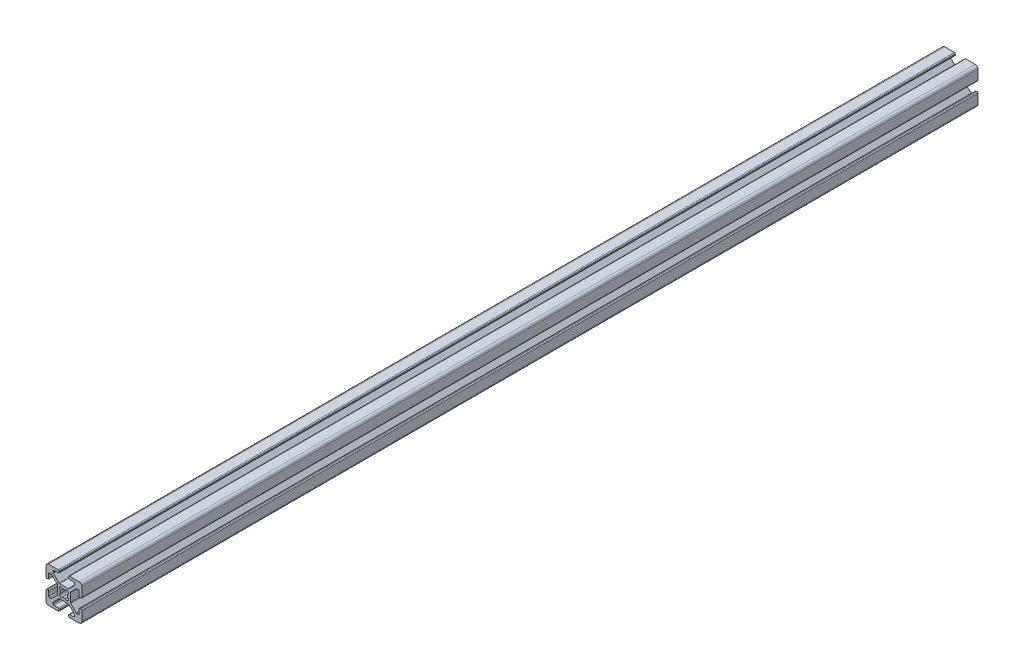
from build123d import *

# Parameters (mm, degrees)
EXTRUDE1_DEPTH = 500


with BuildPart() as part:
    # Sketch1 → Extrude1 (new body)
    with BuildSketch(Plane.XY):
        with BuildLine():
            Line((-5.032287798, -0.341059771), (-5.516287798, -0.341059771))
            ThreePointArc((-5.516287798, -0.341059771), (-5.875498042, -0.192270016), (-6.024287798, 0.166940229))
            Line((-6.024287798, 0.166940229), (-6.024287798, 2.515940229))
            ThreePointArc((-6.024287798, 2.515940229), (-6.173077553, 2.875150474), (-6.532287798, 3.023940229))
            Line((-6.532287798, 3.023940229), (-7.258207136, 3.023940229))
            ThreePointArc((-7.258207136, 3.023940229), (-7.45261032, 2.985271032), (-7.617417381, 2.875150474))
            Line((-7.617417381, 2.875150474), (-10.720498042, -0.227930187))
            ThreePointArc((-10.720498042, -0.227930187), (-10.8306186, -0.392737249), (-10.869287798, -0.587140432))
            Line((-10.869287798, -0.587140432), (-10.869287798, -5.354979109))
            ThreePointArc((-10.869287798, -5.354979109), (-10.8306186, -5.549382293), (-10.720498042, -5.714189354))
            Line((-10.720498042, -5.714189354), (-7.617417381, -8.817270016))
            ThreePointArc((-7.617417381, -8.817270016), (-7.45261032, -8.927390573), (-7.258207136, -8.966059771))
            Line((-7.258207136, -8.966059771), (-6.532287798, -8.966059771))
            ThreePointArc((-6.532287798, -8.966059771), (-6.173077553, -8.817270016), (-6.024287798, -8.458059771))
            Line((-6.024287798, -8.458059771), (-6.024287798, -6.109059771))
            ThreePointArc((-6.024287798, -6.109059771), (-5.875498042, -5.749849526), (-5.516287798, -5.601059771))
            Line((-5.516287798, -5.601059771), (-5.032287798, -5.601059771))
            ThreePointArc((-5.032287798, -5.601059771), (-4.673077553, -5.749849526), (-4.524287798, -6.109059771))
            Line((-4.524287798, -6.109059771), (-4.524287798, -11.471059771))
            ThreePointArc((-4.524287798, -11.471059771), (-4.963627626, -12.531719943), (-6.024287798, -12.971059771))
            Line((-6.024287798, -12.971059771), (-11.386287798, -12.971059771))
            ThreePointArc((-11.386287798, -12.971059771), (-11.745498042, -12.822270016), (-11.894287798, -12.463059771))
            Line((-11.894287798, -12.463059771), (-11.894287798, -11.979059771))
            ThreePointArc((-11.894287798, -11.979059771), (-11.745498042, -11.619849526), (-11.386287798, -11.471059771))
            Line((-11.386287798, -11.471059771), (-9.037287798, -11.471059771))
            ThreePointArc((-9.037287798, -11.471059771), (-8.678077553, -11.322270016), (-8.529287798, -10.963059771))
            Line((-8.529287798, -10.963059771), (-8.529287798, -10.237140432))
            ThreePointArc((-8.529287798, -10.237140432), (-8.567956995, -10.042737249), (-8.678077553, -9.877930187))
            Line((-8.678077553, -9.877930187), (-11.781158214, -6.774849526))
            ThreePointArc((-11.781158214, -6.774849526), (-11.945965275, -6.664728968), (-12.140368459, -6.626059771))
            Line((-12.140368459, -6.626059771), (-16.908207136, -6.626059771))
            ThreePointArc((-16.908207136, -6.626059771), (-17.10261032, -6.664728968), (-17.267417381, -6.774849526))
            Line((-17.267417381, -6.774849526), (-20.370498042, -9.877930187))
            ThreePointArc((-20.370498042, -9.877930187), (-20.4806186, -10.042737249), (-20.519287798, -10.237140432))
            Line((-20.519287798, -10.237140432), (-20.519287798, -10.963059771))
            ThreePointArc((-20.519287798, -10.963059771), (-20.370498042, -11.322270016), (-20.011287798, -11.471059771))
            Line((-20.011287798, -11.471059771), (-17.662287798, -11.471059771))
            ThreePointArc((-17.662287798, -11.471059771), (-17.303077553, -11.619849526), (-17.154287798, -11.979059771))
            Line((-17.154287798, -11.979059771), (-17.154287798, -12.463059771))
            ThreePointArc((-17.154287798, -12.463059771), (-17.303077553, -12.822270016), (-17.662287798, -12.971059771))
            Line((-17.662287798, -12.971059771), (-23.024287798, -12.971059771))
            ThreePointArc((-23.024287798, -12.971059771), (-24.084947969, -12.531719943), (-24.524287798, -11.471059771))
            Line((-24.524287798, -11.471059771), (-24.524287798, -6.109059771))
            ThreePointArc((-24.524287798, -6.109059771), (-24.375498042, -5.749849526), (-24.016287798, -5.601059771))
            Line((-24.016287798, -5.601059771), (-23.532287798, -5.601059771))
            ThreePointArc((-23.532287798, -5.601059771), (-23.173077553, -5.749849526), (-23.024287798, -6.109059771))
            Line((-23.024287798, -6.109059771), (-23.024287798, -8.458059771))
            ThreePointArc((-23.024287798, -8.458059771), (-22.875498042, -8.817270016), (-22.516287798, -8.966059771))
            Line((-22.516287798, -8.966059771), (-21.790368459, -8.966059771))
            ThreePointArc((-21.790368459, -8.966059771), (-21.595965275, -8.927390573), (-21.431158214, -8.817270016))
            Line((-21.431158214, -8.817270016), (-18.328077553, -5.714189354))
            ThreePointArc((-18.328077553, -5.714189354), (-18.217956995, -5.549382293), (-18.179287798, -5.354979109))
            Line((-18.179287798, -5.354979109), (-18.179287798, -0.587140432))
            ThreePointArc((-18.179287798, -0.587140432), (-18.217956995, -0.392737249), (-18.328077553, -0.227930187))
            Line((-18.328077553, -0.227930187), (-21.431158214, 2.875150474))
            ThreePointArc((-21.431158214, 2.875150474), (-21.595965275, 2.985271032), (-21.790368459, 3.023940229))
            Line((-21.790368459, 3.023940229), (-22.516287798, 3.023940229))
            ThreePointArc((-22.516287798, 3.023940229), (-22.875498042, 2.875150474), (-23.024287798, 2.515940229))
            Line((-23.024287798, 2.515940229), (-23.024287798, 0.166940229))
            ThreePointArc((-23.024287798, 0.166940229), (-23.173077553, -0.192270016), (-23.532287798, -0.341059771))
            Line((-23.532287798, -0.341059771), (-24.016287798, -0.341059771))
            ThreePointArc((-24.016287798, -0.341059771), (-24.375498042, -0.192270016), (-24.524287798, 0.166940229))
            Line((-24.524287798, 0.166940229), (-24.524287798, 5.528940229))
            ThreePointArc((-24.524287798, 5.528940229), (-24.084947969, 6.589600401), (-23.024287798, 7.028940229))
            Line((-23.024287798, 7.028940229), (-17.662287798, 7.028940229))
            ThreePointArc((-17.662287798, 7.028940229), (-17.303077553, 6.880150474), (-17.154287798, 6.520940229))
            Line((-17.154287798, 6.520940229), (-17.154287798, 6.036940229))
            ThreePointArc((-17.154287798, 6.036940229), (-17.303077553, 5.677729984), (-17.662287798, 5.528940229))
            Line((-17.662287798, 5.528940229), (-20.011287798, 5.528940229))
            ThreePointArc((-20.011287798, 5.528940229), (-20.370498042, 5.380150474), (-20.519287798, 5.020940229))
            Line((-20.519287798, 5.020940229), (-20.519287798, 4.295020891))
            ThreePointArc((-20.519287798, 4.295020891), (-20.4806186, 4.100617707), (-20.370498042, 3.935810646))
            Line((-20.370498042, 3.935810646), (-17.267417381, 0.832729984))
            ThreePointArc((-17.267417381, 0.832729984), (-17.10261032, 0.722609427), (-16.908207136, 0.683940229))
            Line((-16.908207136, 0.683940229), (-12.140368459, 0.683940229))
            ThreePointArc((-12.140368459, 0.683940229), (-11.945965275, 0.722609427), (-11.781158214, 0.832729984))
            Line((-11.781158214, 0.832729984), (-8.678077553, 3.935810646))
            ThreePointArc((-8.678077553, 3.935810646), (-8.567956995, 4.100617707), (-8.529287798, 4.295020891))
            Line((-8.529287798, 4.295020891), (-8.529287798, 5.020940229))
            ThreePointArc((-8.529287798, 5.020940229), (-8.678077553, 5.380150474), (-9.037287798, 5.528940229))
            Line((-9.037287798, 5.528940229), (-11.386287798, 5.528940229))
            ThreePointArc((-11.386287798, 5.528940229), (-11.745498042, 5.677729984), (-11.894287798, 6.036940229))
            Line((-11.894287798, 6.036940229), (-11.894287798, 6.520940229))
            ThreePointArc((-11.894287798, 6.520940229), (-11.745498042, 6.880150474), (-11.386287798, 7.028940229))
            Line((-11.386287798, 7.028940229), (-6.024287798, 7.028940229))
            ThreePointArc((-6.024287798, 7.028940229), (-4.963627626, 6.589600401), (-4.524287798, 5.528940229))
            Line((-4.524287798, 5.528940229), (-4.524287798, 0.166940229))
            ThreePointArc((-4.524287798, 0.166940229), (-4.673077553, -0.192270016), (-5.032287798, -0.341059771))
        make_face()
        with BuildLine():
            Line((-12.399386954, -5.275565737), (-12.219781831, -5.095960615))
            ThreePointArc((-12.219781831, -5.095960615), (-12.018349781, -4.327527582), (-12.589154291, -3.775036489))
            ThreePointArc((-12.589154291, -3.775036489), (-12.428787798, -2.971059771), (-12.589154291, -2.167083053))
            ThreePointArc((-12.589154291, -2.167083053), (-12.018349781, -1.61459196), (-12.219781831, -0.846158927))
            Line((-12.219781831, -0.846158927), (-12.399386954, -0.666553805))
            ThreePointArc((-12.399386954, -0.666553805), (-13.167819987, -0.465121754), (-13.72031108, -1.035926265))
            ThreePointArc((-13.72031108, -1.035926265), (-14.524287798, -0.875559771), (-15.328264516, -1.035926265))
            ThreePointArc((-15.328264516, -1.035926265), (-15.880755608, -0.465121754), (-16.649188641, -0.666553805))
            Line((-16.649188641, -0.666553805), (-16.828793764, -0.846158927))
            ThreePointArc((-16.828793764, -0.846158927), (-17.030225814, -1.61459196), (-16.459421304, -2.167083053))
            ThreePointArc((-16.459421304, -2.167083053), (-16.619787798, -2.971059771), (-16.459421304, -3.775036489))
            ThreePointArc((-16.459421304, -3.775036489), (-17.030225814, -4.327527582), (-16.828793764, -5.095960615))
            Line((-16.828793764, -5.095960615), (-16.649188641, -5.275565737))
            ThreePointArc((-16.649188641, -5.275565737), (-15.880755608, -5.476997788), (-15.328264516, -4.906193277))
            ThreePointArc((-15.328264516, -4.906193277), (-14.524287798, -5.066559771), (-13.72031108, -4.906193277))
            ThreePointArc((-13.72031108, -4.906193277), (-13.167819987, -5.476997788), (-12.399386954, -5.275565737))
        make_face(mode=Mode.SUBTRACT)
    extrude(amount=EXTRUDE1_DEPTH)


solid = part.part
